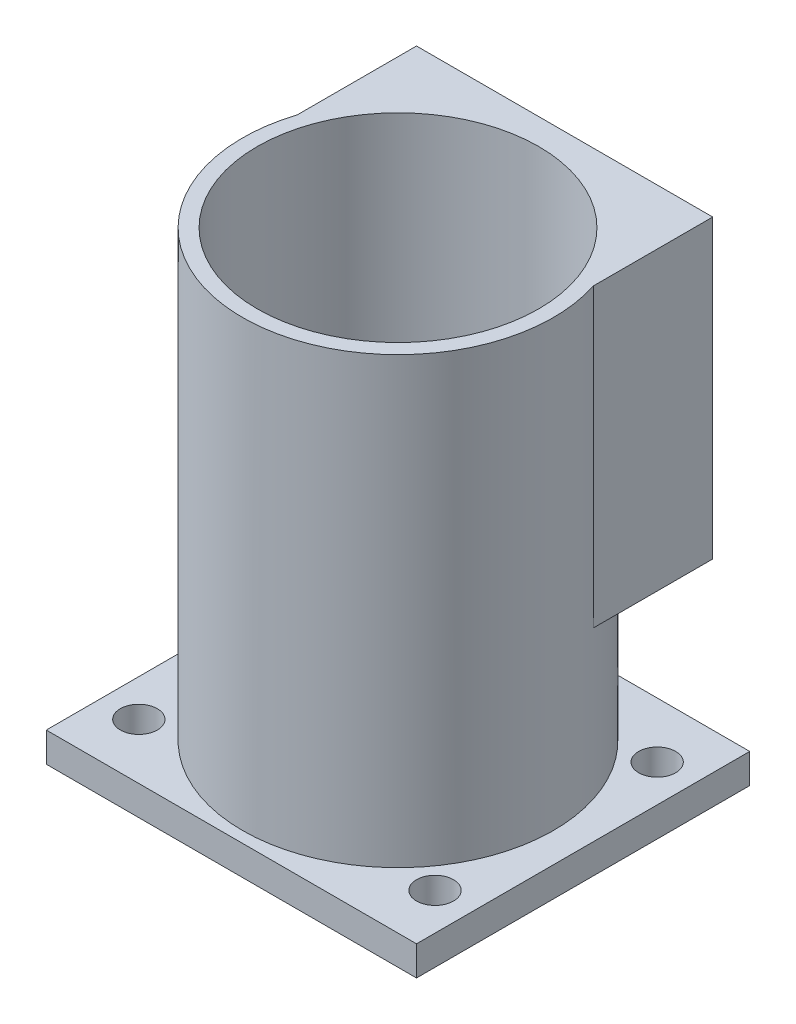
from build123d import *

# Parameters (mm, degrees)
SKETCH1_W           = 63.5
SKETCH1_H           = 57.15
SKETCH1_R           = 3.175
BOSS_EXTRUDE1_DEPTH = 5.08
SKETCH2_R           = 26.67
SKETCH2_R_2         = 24.13
BOSS_EXTRUDE2_DEPTH = 76.2
BOSS_EXTRUDE3_REACH = 59.15
SKETCH4_W           = 50.8
SKETCH4_H           = 50.8


with BuildPart() as part:
    # Sketch1 → Boss-Extrude1 (new body)
    with BuildSketch(Plane(origin=(0, 0, 0), x_dir=(1, 0, 0), z_dir=(0, 1, 0))):
        with Locations((31.75, -28.575)):
            Rectangle(SKETCH1_W, SKETCH1_H)
        with Locations((6.35, -9.525)):
            Circle(SKETCH1_R, mode=Mode.SUBTRACT)
        with Locations((57.15, -9.525)):
            Circle(SKETCH1_R, mode=Mode.SUBTRACT)
        with Locations((57.15, -47.625)):
            Circle(SKETCH1_R, mode=Mode.SUBTRACT)
        with Locations((6.35, -47.625)):
            Circle(SKETCH1_R, mode=Mode.SUBTRACT)
    extrude(amount=BOSS_EXTRUDE1_DEPTH)

    # Sketch2 → Boss-Extrude2 (add)
    with BuildSketch(Plane(origin=(0, 5.08, 0), x_dir=(1, 0, 0), z_dir=(0, 1, 0))):
        with Locations((31.75, -28.575)):
            Circle(SKETCH2_R)
        with Locations((31.75, -28.575)):
            Circle(SKETCH2_R_2, mode=Mode.SUBTRACT)
    extrude(amount=BOSS_EXTRUDE2_DEPTH)

    # Sketch4 → Boss-Extrude3 (add, up to next)
    with BuildSketch(Plane(origin=(0, 0, 0), x_dir=(-1, 0, 0), z_dir=(0, 0, -1)), mode=Mode.PRIVATE) as boss_extrude3_sk1:
        with Locations((-31.75, 55.88)):
            Rectangle(SKETCH4_W, SKETCH4_H)
    boss_extrude3_tool1 = extrude(boss_extrude3_sk1.sketch, amount=-BOSS_EXTRUDE3_REACH, mode=Mode.PRIVATE) - part.part
    add(boss_extrude3_tool1.solids().sort_by_distance((31.75, 55.88, 0))[0])


solid = part.part
